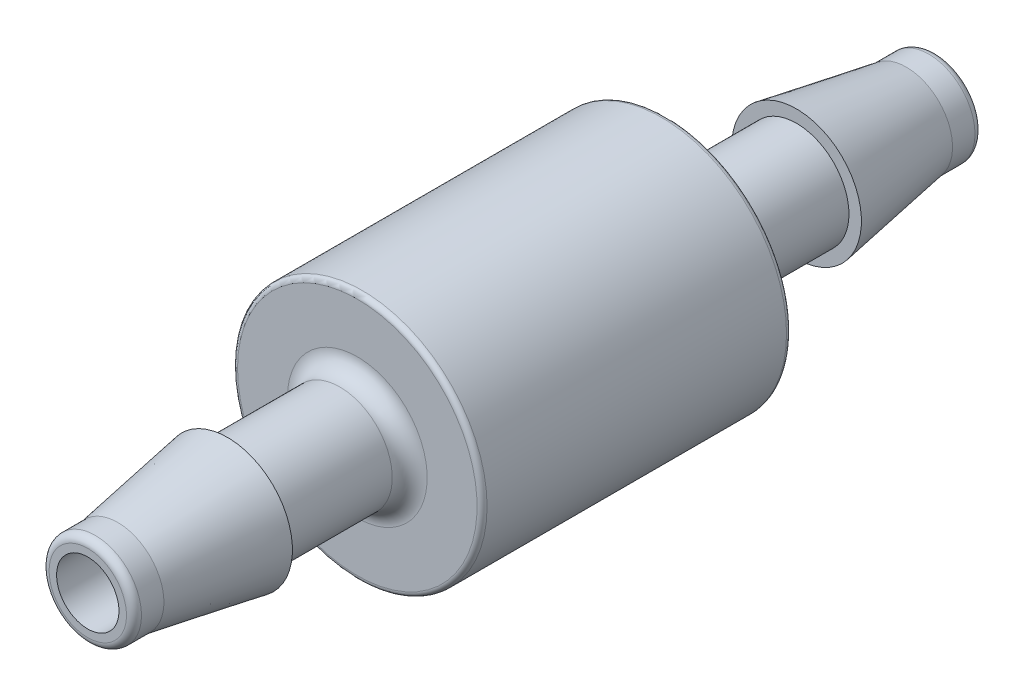
from build123d import *


with BuildPart() as part:
    # Sketch2 → Revolve1 (revolve)
    with BuildSketch(Plane(origin=(0, 0, 0), x_dir=(0, 0, -1), z_dir=(1, 0, 0)), mode=Mode.PRIVATE) as revolve1_sk:
        with BuildLine():
            Line((-21.59, 1.5875), (-21.59, 1.9685))
            ThreePointArc((-21.59, 1.9685), (-21.478407684, 2.237907684), (-21.209, 2.3495))
            Line((-21.209, 2.3495), (-20.066, 2.3495))
            Line((-20.066, 2.3495), (-14.478, 3.302))
            Line((-14.478, 3.302), (-14.478, 2.667))
            Line((-14.478, 2.667), (-8.763, 2.667))
            ThreePointArc((-8.763, 2.667), (-8.134382072, 2.927382072), (-7.874, 3.556))
            Line((-7.874, 3.556), (-7.874, 6.096))
            ThreePointArc((-7.874, 6.096), (-7.799605122, 6.275605122), (-7.62, 6.35))
            Line((-7.62, 6.35), (7.62, 6.35))
            ThreePointArc((7.62, 6.35), (7.799605122, 6.275605122), (7.874, 6.096))
            Line((7.874, 6.096), (7.874, 3.556))
            ThreePointArc((7.874, 3.556), (8.134382072, 2.927382072), (8.763, 2.667))
            Line((8.763, 2.667), (14.478, 2.667))
            Line((14.478, 2.667), (14.478, 3.302))
            Line((14.478, 3.302), (20.066, 2.3495))
            Line((20.066, 2.3495), (21.209, 2.3495))
            ThreePointArc((21.209, 2.3495), (21.478407684, 2.237907684), (21.59, 1.9685))
            Line((21.59, 1.9685), (21.59, 1.5875))
            Line((21.59, 1.5875), (-21.59, 1.5875))
        make_face()
    revolve(revolve1_sk.sketch.rotate(Axis((0, 0, -21.59), (0, 0, 1)), 90), axis=Axis((0, 0, -21.59), (0, 0, 1)))


solid = part.part
